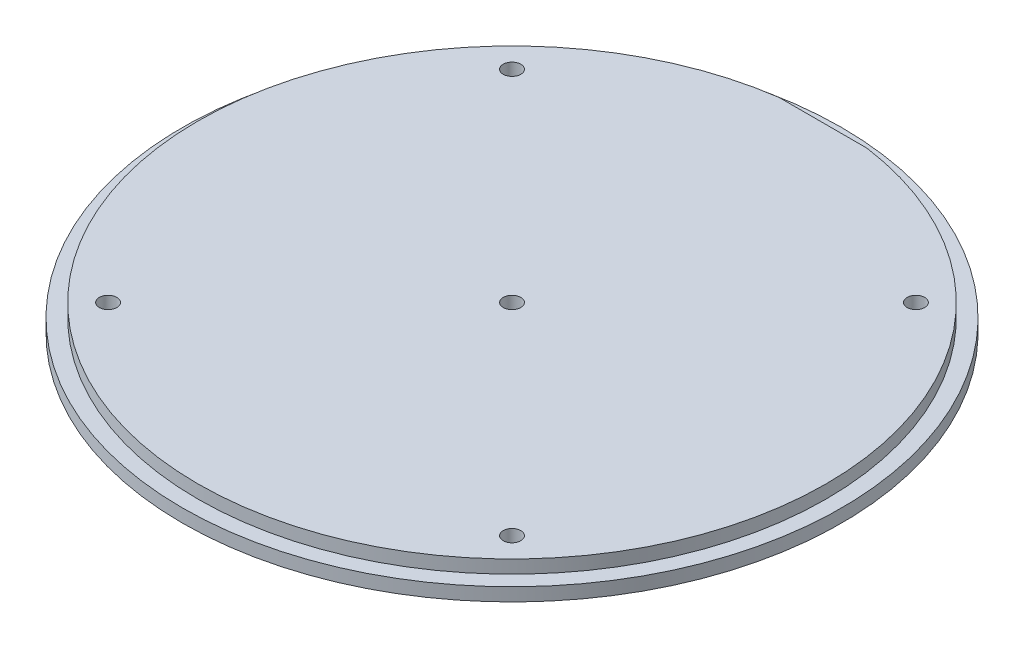
from build123d import *

# Parameters (mm, degrees)
SKETCH1_R                    = 75
BOSS_EXTRUDE1_DEPTH          = 3
SKETCH2_R                    = 71.5
BOSS_EXTRUDE2_DEPTH          = 3
SKETCH3_R                    = 2
CUT_EXTRUDE1_DEPTH           = 7
CHAMFER1_SIZE                = 2
CIRPATTERN1_COUNT            = 4
CHAMFER1_OF_CIRPATTERN1_SIZE = 2
SKETCH4_R                    = 2
CUT_EXTRUDE2_DEPTH           = 7
CHAMFER2_SIZE                = 2
CUT_EXTRUDE4_DEPTH           = 3


with BuildPart() as part:
    # Sketch1 → Boss-Extrude1 (new body)
    with BuildSketch(Plane(origin=(0, 0, 0), x_dir=(1, 0, 0), z_dir=(0, 1, 0))):
        Circle(SKETCH1_R)
    extrude(amount=BOSS_EXTRUDE1_DEPTH)

    # Sketch2 → Boss-Extrude2 (add)
    with BuildSketch(Plane(origin=(0, 3, 0), x_dir=(1, 0, 0), z_dir=(0, 1, 0))):
        Circle(SKETCH2_R)
    extrude(amount=BOSS_EXTRUDE2_DEPTH)

    # Sketch3 → Cut-Extrude1 (cut, through all)
    with BuildSketch(Plane.XZ):
        with Locations((45.961940777, 45.961940777)):
            Circle(SKETCH3_R)
    cut_extrude1 = extrude(amount=-CUT_EXTRUDE1_DEPTH, mode=Mode.SUBTRACT)

    # Chamfer1
    chamfer1_edges = [part.edges().sort_by_distance(p)[0] for p in [
        (43.961940777, 0, 45.961940777),
    ]]
    chamfer(chamfer1_edges, length=CHAMFER1_SIZE)

    # CirPattern1: Cut-Extrude1 ×4 about axis
    cirpattern1_axis = Axis((0, 0, 0), (0, 1, 0))
    for i in range(1, CIRPATTERN1_COUNT):
        add(cut_extrude1.rotate(cirpattern1_axis, i * 360 / CIRPATTERN1_COUNT), mode=Mode.SUBTRACT)

    # Chamfer1 of CirPattern1
    chamfer1_of_cirpattern1_edges = [part.edges().sort_by_distance(p)[0] for p in [
        (45.961940777, 0, -43.961940777),
        (-43.961940777, 0, -45.961940777),
        (-45.961940777, 0, 43.961940777),
    ]]
    chamfer(chamfer1_of_cirpattern1_edges, length=CHAMFER1_OF_CIRPATTERN1_SIZE)

    # Sketch4 → Cut-Extrude2 (cut, through all)
    with BuildSketch(Plane.XZ):
        Circle(SKETCH4_R)
    extrude(amount=-CUT_EXTRUDE2_DEPTH, mode=Mode.SUBTRACT)

    # Chamfer2
    chamfer2_edges = [part.edges().sort_by_distance(p)[0] for p in [
        (-2, 0, 0),
    ]]
    chamfer(chamfer2_edges, length=CHAMFER2_SIZE)

    # Sketch5 → Cut-Extrude4 (cut)
    with BuildSketch(Plane(origin=(0, 6, 0), x_dir=(1, 0, 0), z_dir=(0, 1, 0))):
        with BuildLine():
            Line((-10, 70.797245709), (10, 70.797245709))
            ThreePointArc((10, 70.797245709), (0, 71.5), (-10, 70.797245709))
        make_face()
    extrude(amount=-CUT_EXTRUDE4_DEPTH, mode=Mode.SUBTRACT)


solid = part.part
